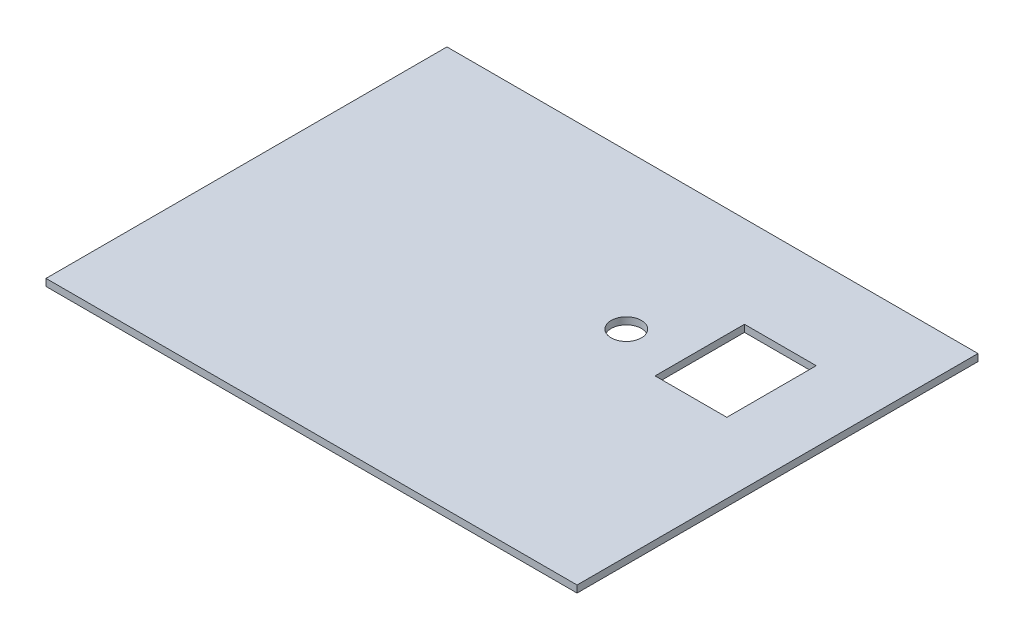
from build123d import *

# Parameters (mm, degrees)
SKETCH1_W           = 191.77
SKETCH1_H           = 144.78
SKETCH1_R           = 5.461
SKETCH1_W_2         = 25.908
SKETCH1_H_2         = 32.2834
BOSS_EXTRUDE1_DEPTH = 2.54


with BuildPart() as part:
    # Sketch1 → Boss-Extrude1 (new body)
    with BuildSketch(Plane(origin=(0, 0, 0), x_dir=(1, 0, 0), z_dir=(0, 1, 0))):
        with Locations((95.885, 72.39)):
            Rectangle(SKETCH1_W, SKETCH1_H)
        with Locations(Location((120.65, 88.9, 0), (0, 0, 270))):  # turned: the seam where the file's is
            Circle(SKETCH1_R, mode=Mode.SUBTRACT)
        with Locations((153.416, 95.6183)):
            Rectangle(SKETCH1_W_2, SKETCH1_H_2, mode=Mode.SUBTRACT)
    extrude(amount=BOSS_EXTRUDE1_DEPTH)


solid = part.part
